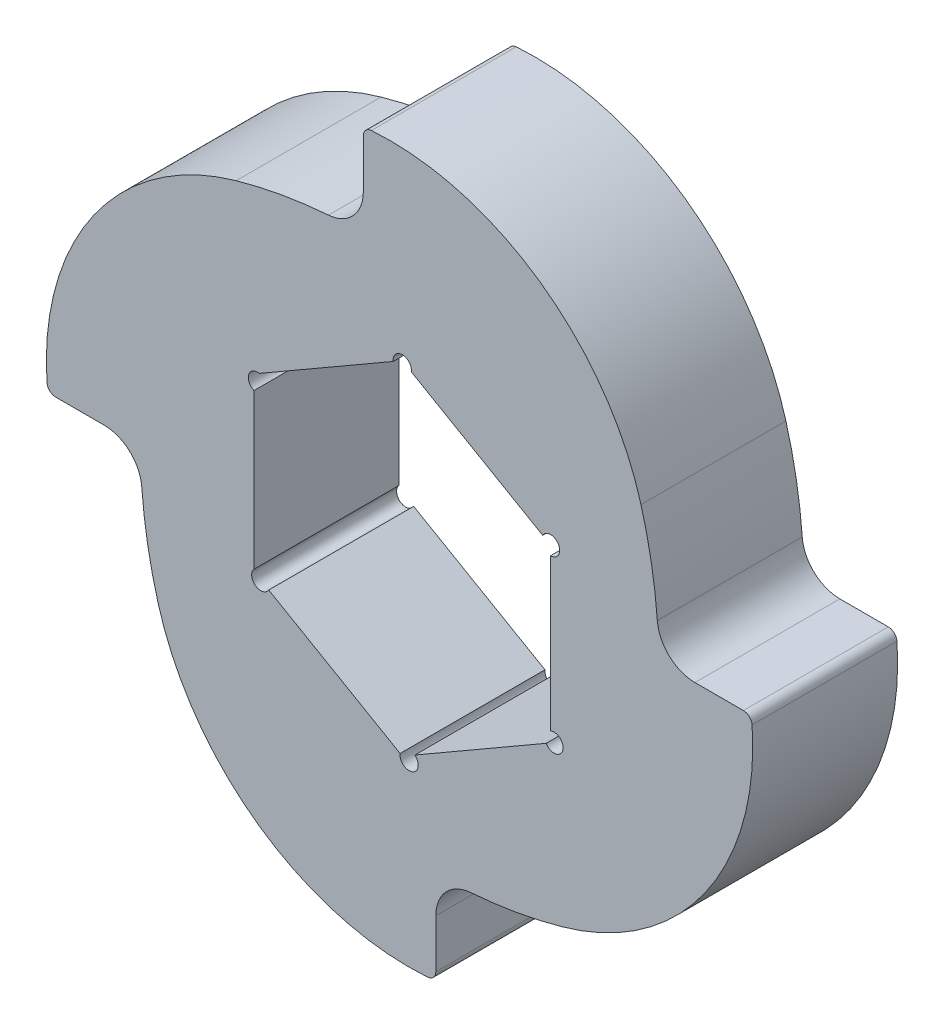
from build123d import *

# Parameters (mm, degrees)
SKETCH1_R           = 16
BOSS_EXTRUDE1_DEPTH = 6.35
SKETCH2_OUTSIDE_W   = 43.14
SKETCH2_OUTSIDE_H   = 43.14
CUT_EXTRUDE1_DEPTH  = 7.35
CUT_EXTRUDE2_DEPTH  = 7.35
CUT_EXTRUDE3_REACH  = 8.35
SKETCH4_R           = 0.4


with BuildPart() as part:
    # Sketch1 → Boss-Extrude1 (new body)
    with BuildSketch(Plane.XY):
        Circle(SKETCH1_R)
    extrude(amount=BOSS_EXTRUDE1_DEPTH)

    # Sketch2 outside → Cut-Extrude1 (cut, through all)
    with BuildSketch(Plane.XY.offset(6.35)):
        Rectangle(SKETCH2_OUTSIDE_W, SKETCH2_OUTSIDE_H)
        with BuildLine():
            Line((14.949348906, 1.700814958), (12.823807348, 1.700814958))
            ThreePointArc((12.823807348, 1.700814958), (11.700778028, 2.141605825), (11.177410812, 3.228610057))
            ThreePointArc((11.177410812, 3.228610057), (10.921226769, 5.268595293), (10.461728017, 7.272599017))
            ThreePointArc((10.461728017, 7.272599017), (6.02807025, 13.518558738), (-1.353723941, 15.562684117))
            ThreePointArc((-1.353723941, 15.562684117), (-1.605363135, 15.44226057), (-1.707494519, 15.182658383))
            Line((-1.707494519, 15.182658383), (-1.707494519, 13.057116825))
            ThreePointArc((-1.707494519, 13.057116825), (-2.148285386, 11.934087504), (-3.235289619, 11.410720289))
            ThreePointArc((-3.235289619, 11.410720289), (-5.275274855, 11.154536246), (-7.279278578, 10.695037493))
            ThreePointArc((-7.279278578, 10.695037493), (-13.525238299, 6.261379727), (-15.569363679, -1.120414464))
            ThreePointArc((-15.569363679, -1.120414464), (-15.448940131, -1.372053658), (-15.189337945, -1.474185042))
            Line((-15.189337945, -1.474185042), (-13.063796386, -1.474185042))
            ThreePointArc((-13.063796386, -1.474185042), (-11.940767066, -1.914975909), (-11.417399851, -3.001980142))
            ThreePointArc((-11.417399851, -3.001980142), (-11.161215808, -5.041965378), (-10.701717055, -7.045969101))
            ThreePointArc((-10.701717055, -7.045969101), (-6.268059288, -13.291928823), (1.113734902, -15.336054202))
            ThreePointArc((1.113734902, -15.336054202), (1.365374097, -15.215630654), (1.467505481, -14.956028468))
            Line((1.467505481, -14.956028468), (1.467505481, -12.830486909))
            ThreePointArc((1.467505481, -12.830486909), (1.908296348, -11.707457589), (2.99530058, -11.184090374))
            ThreePointArc((2.99530058, -11.184090374), (5.035285816, -10.927906331), (7.03928954, -10.468407578))
            ThreePointArc((7.03928954, -10.468407578), (13.285249261, -6.034749811), (15.32937464, 1.347044379))
            ThreePointArc((15.32937464, 1.347044379), (15.208951093, 1.598683573), (14.949348906, 1.700814958))
        make_face(mode=Mode.SUBTRACT)
    extrude(amount=-CUT_EXTRUDE1_DEPTH, mode=Mode.SUBTRACT)

    # Sketch3 → Cut-Extrude2 (cut, through all)
    with BuildSketch(Plane.XY.offset(6.35)):
        Polygon((0, 7.505553499), (-6.5, 3.75277675), (-6.5, -3.75277675), (0, -7.505553499), (6.5, -3.75277675), (6.5, 3.75277675), align=None)
    extrude(amount=-CUT_EXTRUDE2_DEPTH, mode=Mode.SUBTRACT)

    # Sketch4 → Cut-Extrude3 (cut, up to next)
    with BuildSketch(Plane(origin=(0, 0, 0), x_dir=(-1, 0, 0), z_dir=(0, 0, -1)), mode=Mode.PRIVATE) as cut_extrude3_sk1:
        with Locations((-6.5, 3.75277675)):
            Circle(SKETCH4_R)
    cut_extrude3_tool1 = extrude(cut_extrude3_sk1.sketch, amount=-CUT_EXTRUDE3_REACH, mode=Mode.PRIVATE) & part.part
    add(cut_extrude3_tool1.solids().sort_by_distance((6.5, 3.752777, 0))[0], mode=Mode.SUBTRACT)
    # Sketch4 → Cut-Extrude3 (cut, up to next)
    with BuildSketch(Plane(origin=(0, 0, 0), x_dir=(-1, 0, 0), z_dir=(0, 0, -1)), mode=Mode.PRIVATE) as cut_extrude3_sk2:
        with Locations((0, 7.332348419)):
            Circle(SKETCH4_R)
    cut_extrude3_tool2 = extrude(cut_extrude3_sk2.sketch, amount=-CUT_EXTRUDE3_REACH, mode=Mode.PRIVATE) & part.part
    add(cut_extrude3_tool2.solids().sort_by_distance((0, 7.332348, 0))[0], mode=Mode.SUBTRACT)
    # Sketch4 → Cut-Extrude3 (cut, up to next)
    with BuildSketch(Plane(origin=(0, 0, 0), x_dir=(-1, 0, 0), z_dir=(0, 0, -1)), mode=Mode.PRIVATE) as cut_extrude3_sk3:
        with Locations((6.35, 3.492969129)):
            Circle(SKETCH4_R)
    cut_extrude3_tool3 = extrude(cut_extrude3_sk3.sketch, amount=-CUT_EXTRUDE3_REACH, mode=Mode.PRIVATE) & part.part
    add(cut_extrude3_tool3.solids().sort_by_distance((-6.35, 3.492969, 0))[0], mode=Mode.SUBTRACT)
    # Sketch4 → Cut-Extrude3 (cut, up to next)
    with BuildSketch(Plane(origin=(0, 0, 0), x_dir=(-1, 0, 0), z_dir=(0, 0, -1)), mode=Mode.PRIVATE) as cut_extrude3_sk4:
        with Locations((6.2, -3.92598183)):
            Circle(SKETCH4_R)
    cut_extrude3_tool4 = extrude(cut_extrude3_sk4.sketch, amount=-CUT_EXTRUDE3_REACH, mode=Mode.PRIVATE) & part.part
    add(cut_extrude3_tool4.solids().sort_by_distance((-6.2, -3.925982, 0))[0], mode=Mode.SUBTRACT)
    # Sketch4 → Cut-Extrude3 (cut, up to next)
    with BuildSketch(Plane(origin=(0, 0, 0), x_dir=(-1, 0, 0), z_dir=(0, 0, -1)), mode=Mode.PRIVATE) as cut_extrude3_sk5:
        with Locations((-0.3, -7.505553499)):
            Circle(SKETCH4_R)
    cut_extrude3_tool5 = extrude(cut_extrude3_sk5.sketch, amount=-CUT_EXTRUDE3_REACH, mode=Mode.PRIVATE) & part.part
    add(cut_extrude3_tool5.solids().sort_by_distance((0.3, -7.505553, 0))[0], mode=Mode.SUBTRACT)
    # Sketch4 → Cut-Extrude3 (cut, up to next)
    with BuildSketch(Plane(origin=(0, 0, 0), x_dir=(-1, 0, 0), z_dir=(0, 0, -1)), mode=Mode.PRIVATE) as cut_extrude3_sk6:
        with Locations((-6.65, -3.666174209)):
            Circle(SKETCH4_R)
    cut_extrude3_tool6 = extrude(cut_extrude3_sk6.sketch, amount=-CUT_EXTRUDE3_REACH, mode=Mode.PRIVATE) & part.part
    add(cut_extrude3_tool6.solids().sort_by_distance((6.65, -3.666174, 0))[0], mode=Mode.SUBTRACT)


solid = part.part
